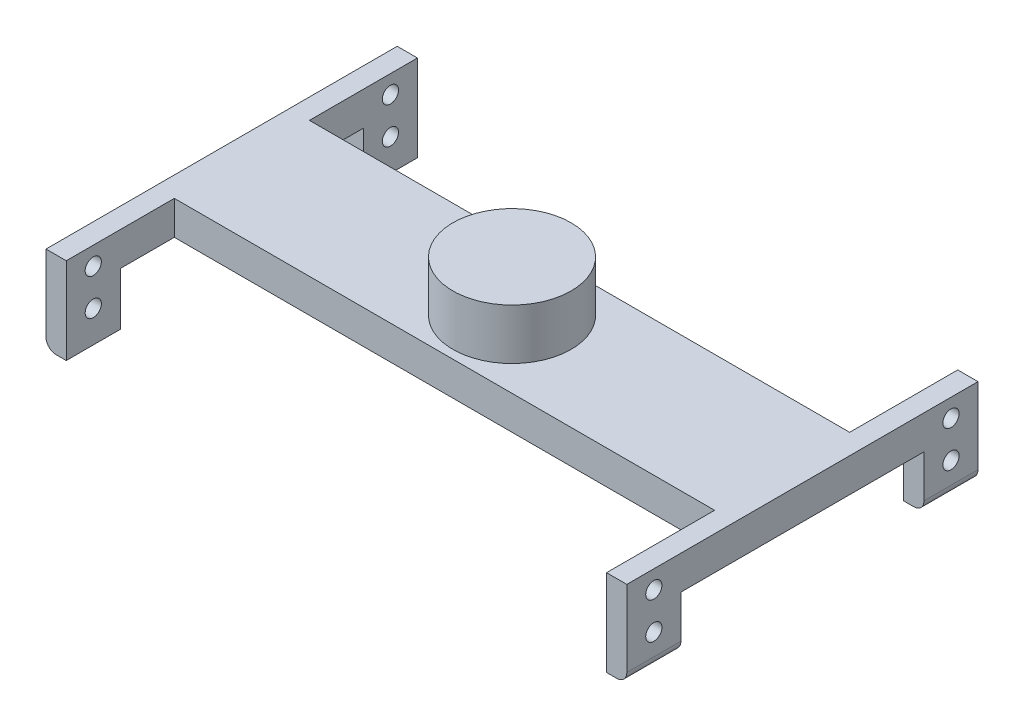
from build123d import *

# Parameters (mm, degrees)
SKETCH1_W                = 80
SKETCH1_H                = 20
BOSS_EXTRUDE1_DEPTH      = 2.5
BOSS_EXTRUDE1_DEPTH_BACK = 2.5
BOSS_EXTRUDE2_DEPTH      = 3
FILLET1_R                = 1.5
SKETCH3_R                = 1.2
CUT_EXTRUDE1_DEPTH       = 1
CUT_EXTRUDE1_DEPTH_BACK  = 87
BOSS_EXTRUDE3_START      = 2.5
SKETCH4_R                = 8.75
BOSS_EXTRUDE3_DEPTH      = 7.5


with BuildPart() as part:
    # Sketch1 → Boss-Extrude1 (new body, two sides)
    with BuildSketch(Plane(origin=(0, 0, 0), x_dir=(1, 0, 0), z_dir=(0, 1, 0))) as boss_extrude1_sk:
        Rectangle(SKETCH1_W, SKETCH1_H)
    extrude(amount=BOSS_EXTRUDE1_DEPTH)
    extrude(boss_extrude1_sk.sketch, amount=-BOSS_EXTRUDE1_DEPTH_BACK)

    # Sketch2 → Boss-Extrude2 (add)
    with BuildSketch(Plane(origin=(40, 0, 0), x_dir=(0, 0, -1), z_dir=(1, 0, 0))):
        Polygon((-26, 2.5), (26, 2.5), (26, -10.3), (18, -10.3), (18, -2.5), (-18, -2.5), (-18, -10.3), (-26, -10.3), align=None)
    boss_extrude2 = extrude(amount=BOSS_EXTRUDE2_DEPTH)

    # Mirror2: Boss-Extrude2 across plane
    add(boss_extrude2.mirror(Plane(origin=(0, 0, 0), x_dir=(0, 0, 1), z_dir=(1, 0, 0))))

    # Fillet1
    fillet1_edges = [part.edges().sort_by_distance(p)[0] for p in [
        (43, -10.3, 22),
        (43, -10.3, -22),
        (-43, -10.3, -22),
        (-43, -10.3, 22),
    ]]
    fillet(fillet1_edges, radius=FILLET1_R)

    # Sketch3 → Cut-Extrude1 (cut, two sides)
    with BuildSketch(Plane(origin=(43, 0, 0), x_dir=(0, 0, -1), z_dir=(1, 0, 0))) as cut_extrude1_sk:
        with Locations((22, -0.2)):
            Circle(SKETCH3_R)
        with Locations((-22, -0.2)):
            Circle(SKETCH3_R)
        with Locations((-22, -5.6)):
            Circle(SKETCH3_R)
        with Locations((22, -5.6)):
            Circle(SKETCH3_R)
    extrude(amount=CUT_EXTRUDE1_DEPTH, mode=Mode.SUBTRACT)
    extrude(cut_extrude1_sk.sketch, amount=-CUT_EXTRUDE1_DEPTH_BACK, mode=Mode.SUBTRACT)

    # Sketch4 → Boss-Extrude3 (add)
    with BuildSketch(Plane(origin=(0, 0, 0), x_dir=(1, 0, 0), z_dir=(0, 1, 0)).offset(BOSS_EXTRUDE3_START)):
        Circle(SKETCH4_R)
    extrude(amount=BOSS_EXTRUDE3_DEPTH)


solid = part.part
